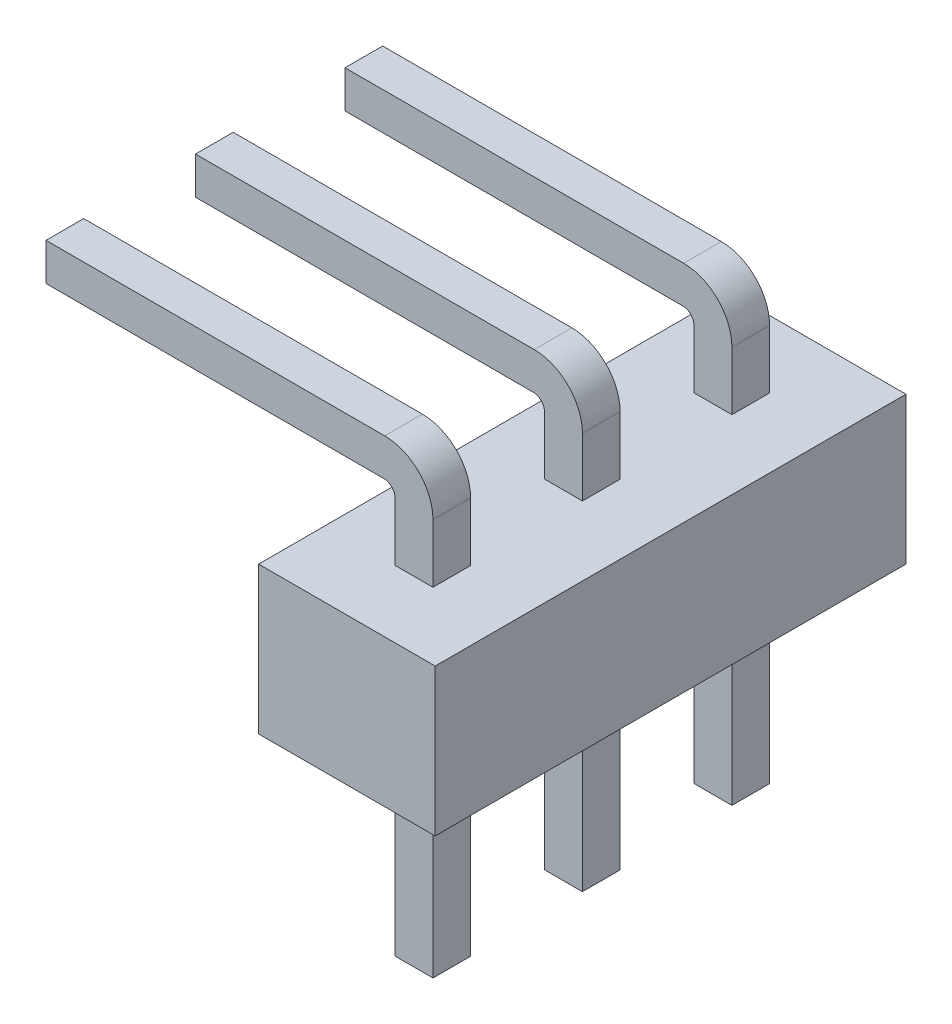
from build123d import *

# Parameters (mm, degrees)
SKETCH1_W       = 3
SKETCH1_H       = 2.5
EXTRUDE1_DEPTH  = 4
SKETCH2_W       = 0.645
SKETCH2_H       = 3.5
EXTRUDE2_DEPTH  = 0.64
LPATTERN1_COUNT = 3
LPATTERN1_PITCH = 2.54
CHAMFER1_SIZE   = 0.25


with BuildPart() as part:
    # Sketch1 → Extrude1 (new body, symmetric)
    with BuildSketch(Plane.XY):
        Rectangle(SKETCH1_W, SKETCH1_H)
    extrude(amount=EXTRUDE1_DEPTH, both=True)

    # Sketch2 → Extrude2 (add)
    with BuildSketch(Plane.XY.offset(2.86)):
        with BuildLine():
            Line((-0.3225, 1.25), (-0.3225, 2.245))
            ThreePointArc((-0.3225, 2.245), (-0.374776878, 2.375), (-0.5025, 2.43261663))
            Line((-0.5025, 2.43261663), (-6.5025, 2.43261663))
            Line((-6.5025, 2.43261663), (-6.5025, 3.06831282))
            Line((-6.5025, 3.06831282), (-0.4975, 3.06831282))
            ThreePointArc((-0.4975, 3.06831282), (0.082527742, 2.826), (0.3225, 2.245))
            Line((0.3225, 2.245), (0.3225, 1.25))
            Line((0.3225, 1.25), (-0.3225, 1.25))
        make_face()
        with Locations((0, -3)):
            Rectangle(SKETCH2_W, SKETCH2_H)
    extrude2 = extrude(amount=-EXTRUDE2_DEPTH)

    # LPattern1: Extrude2 ×3
    with Locations(*[(0, 0, -i * LPATTERN1_PITCH) for i in range(1, LPATTERN1_COUNT)]):
        add(extrude2)

    # Chamfer1
    chamfer1_edges = [part.edges().sort_by_distance(p)[0] for p in [
        (-6.5025, 2.750464725, 2.22),
        (-6.5025, 2.43261663, 2.54),
        (-6.5025, 3.06831282, 2.54),
        (-6.5025, 2.750464725, 2.86),
        (0, -4.75, 2.22),
        (0.3225, -4.75, 2.54),
        (-0.3225, -4.75, 2.54),
        (0, -4.75, 2.86),
        (-6.5025, 2.750464725, -0.32),
        (-6.5025, 2.43261663, 0),
        (-6.5025, 3.06831282, 0),
        (-6.5025, 2.750464725, 0.32),
        (0, -4.75, -0.32),
        (0.3225, -4.75, 0),
        (-0.3225, -4.75, 0),
        (0, -4.75, 0.32),
        (-6.5025, 2.750464725, -2.86),
        (-6.5025, 2.43261663, -2.54),
        (-6.5025, 3.06831282, -2.54),
        (-6.5025, 2.750464725, -2.22),
        (0, -4.75, -2.86),
        (0.3225, -4.75, -2.54),
        (-0.3225, -4.75, -2.54),
        (0, -4.75, -2.22),
    ]]
    chamfer(chamfer1_edges, length=CHAMFER1_SIZE)


solid = part.part
